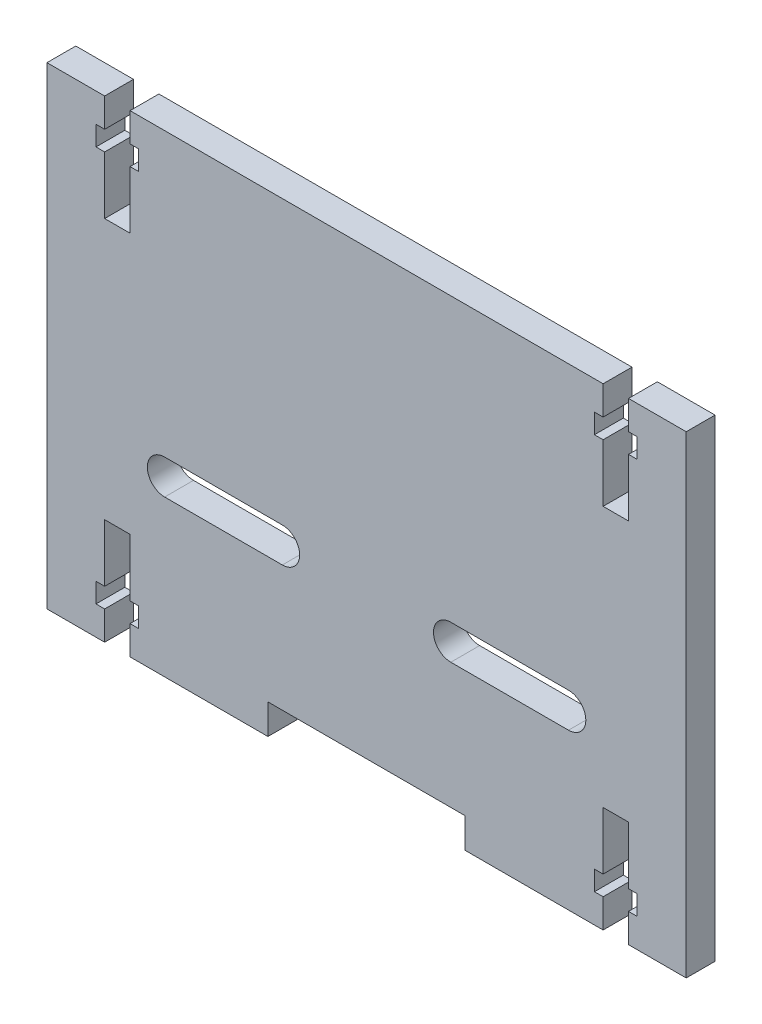
from build123d import *

# Parameters (mm, degrees)
SKETCH1_W           = 110.8
SKETCH1_H           = 82
BOSS_EXTRUDE1_DEPTH = 5
CUT_EXTRUDE1_DEPTH  = 10
SKETCH3_W           = 34.2
SKETCH3_H           = 5.2
CUT_EXTRUDE2_DEPTH  = 10
CUT_EXTRUDE3_DEPTH  = 10


with BuildPart() as part:
    # Sketch1 → Boss-Extrude1 (new body)
    with BuildSketch(Plane.XY):
        Rectangle(SKETCH1_W, SKETCH1_H)
    extrude(amount=BOSS_EXTRUDE1_DEPTH)

    # Sketch2 → Cut-Extrude1 (cut)
    with BuildSketch(Plane.XY.offset(5)):
        Polygon((41, -32.6), (41, -22.6), (45.4, -22.6), (45.4, -32.6), (46.9, -32.6), (46.9, -36), (45.4, -36), (45.4, -41), (41, -41), (41, -36), (39.5, -36), (39.5, -32.6), align=None)
        Polygon((-41, 32.6), (-41, 22.6), (-45.4, 22.6), (-45.4, 32.6), (-46.9, 32.6), (-46.9, 36), (-45.4, 36), (-45.4, 41), (-41, 41), (-41, 36), (-39.5, 36), (-39.5, 32.6), align=None)
        Polygon((45.4, 22.6), (45.4, 32.6), (46.9, 32.6), (46.9, 36), (45.4, 36), (45.4, 41), (41, 41), (41, 36), (39.5, 36), (39.5, 32.6), (41, 32.6), (41, 22.6), align=None)
        Polygon((-45.4, -22.6), (-45.4, -32.6), (-46.9, -32.6), (-46.9, -36), (-45.4, -36), (-45.4, -41), (-41, -41), (-41, -36), (-39.5, -36), (-39.5, -32.6), (-41, -32.6), (-41, -22.6), align=None)
    extrude(amount=-CUT_EXTRUDE1_DEPTH, mode=Mode.SUBTRACT)

    # Sketch3 → Cut-Extrude2 (cut)
    with BuildSketch(Plane.XY.offset(5)):
        with Locations((0, -38.4)):
            Rectangle(SKETCH3_W, SKETCH3_H)
    extrude(amount=-CUT_EXTRUDE2_DEPTH, mode=Mode.SUBTRACT)

    # Sketch4 → Cut-Extrude3 (cut)
    with BuildSketch(Plane.XY.offset(5)):
        with BuildLine():
            Line((35, -14), (14.6, -14))
            ThreePointArc((14.6, -14), (11.6, -11), (14.6, -8))
            Line((14.6, -8), (35, -8))
            ThreePointArc((35, -8), (38, -11), (35, -14))
        make_face()
        with BuildLine():
            Line((-14.6, -8), (-35, -8))
            ThreePointArc((-35, -8), (-38, -11), (-35, -14))
            Line((-35, -14), (-14.6, -14))
            ThreePointArc((-14.6, -14), (-11.6, -11), (-14.6, -8))
        make_face()
    extrude(amount=-CUT_EXTRUDE3_DEPTH, mode=Mode.SUBTRACT)


solid = part.part
